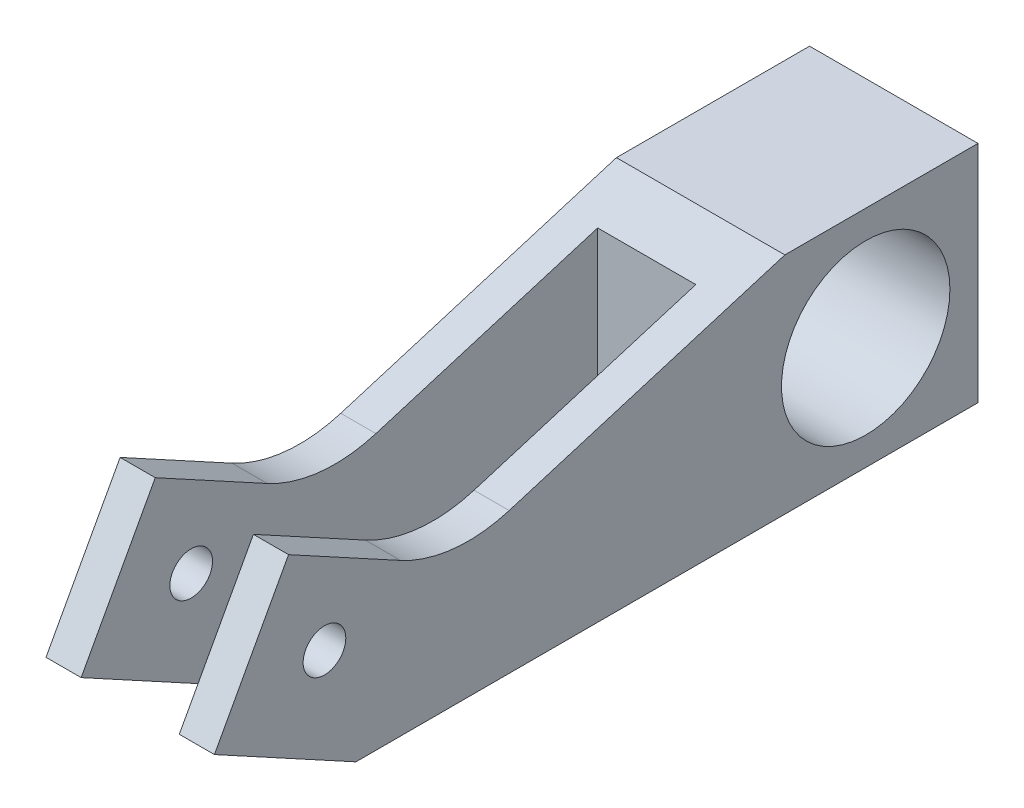
from build123d import *

# Parameters (mm, degrees)
SKETCH1_R           = 9.525
BOSS_EXTRUDE1_DEPTH = 9.525
BOSS_EXTRUDE2_START = 9.525
SKETCH1_4_R         = 9.525
SKETCH1_4_R_2       = 2.413
BOSS_EXTRUDE2_DEPTH = 3.9751
BOSS_EXTRUDE3_START = -9.525
SKETCH1_5_R         = 9.525
SKETCH1_5_R_2       = 2.413
BOSS_EXTRUDE3_DEPTH = 3.9751


with BuildPart() as part:
    # Sketch1 → Boss-Extrude1 (new body, symmetric)
    with BuildSketch(Plane(origin=(0, 0, 0), x_dir=(0, 0, -1), z_dir=(1, 0, 0))):
        Polygon((42.418, 23.552715039), (42.418, 0), (70.358, 0), (70.358, 25.4), (48.514, 25.4), align=None)
        with Locations((57.658, 12.7)):
            Circle(SKETCH1_R, mode=Mode.SUBTRACT)
    extrude(amount=BOSS_EXTRUDE1_DEPTH, both=True)

    # Sketch1_4 → Boss-Extrude2 (add)
    with BuildSketch(Plane(origin=(0, 0, 0), x_dir=(0, 0, -1), z_dir=(1, 0, 0)).offset(BOSS_EXTRUDE2_START)):
        with BuildLine():
            Line((0, 0), (70.358, 0))
            Line((70.358, 0), (70.358, 25.4))
            Line((70.358, 25.4), (48.514, 25.4))
            Line((48.514, 25.4), (17.332880156, 15.95111323))
            ThreePointArc((17.332880156, 15.95111323), (11.05930066, 15.346935831), (5.039023234, 17.212167653))
            Line((5.039023234, 17.212167653), (-7.62, 24.106033067))
            Line((-7.62, 24.106033067), (-16.002, 8.71438754))
            Line((-16.002, 8.71438754), (0, 0))
        make_face()
        with Locations((57.658, 12.7)):
            Circle(SKETCH1_4_R, mode=Mode.SUBTRACT)
        with Locations((-3.556, 12.7)):
            Circle(SKETCH1_4_R_2, mode=Mode.SUBTRACT)
    extrude(amount=-BOSS_EXTRUDE2_DEPTH)

    # Sketch1_5 → Boss-Extrude3 (add)
    with BuildSketch(Plane(origin=(0, 0, 0), x_dir=(0, 0, -1), z_dir=(1, 0, 0)).offset(BOSS_EXTRUDE3_START)):
        with BuildLine():
            Line((0, 0), (70.358, 0))
            Line((70.358, 0), (70.358, 25.4))
            Line((70.358, 25.4), (48.514, 25.4))
            Line((48.514, 25.4), (17.332880156, 15.95111323))
            ThreePointArc((17.332880156, 15.95111323), (11.05930066, 15.346935831), (5.039023234, 17.212167653))
            Line((5.039023234, 17.212167653), (-7.62, 24.106033067))
            Line((-7.62, 24.106033067), (-16.002, 8.71438754))
            Line((-16.002, 8.71438754), (0, 0))
        make_face()
        with Locations((57.658, 12.7)):
            Circle(SKETCH1_5_R, mode=Mode.SUBTRACT)
        with Locations((-3.556, 12.7)):
            Circle(SKETCH1_5_R_2, mode=Mode.SUBTRACT)
    extrude(amount=BOSS_EXTRUDE3_DEPTH)


solid = part.part
